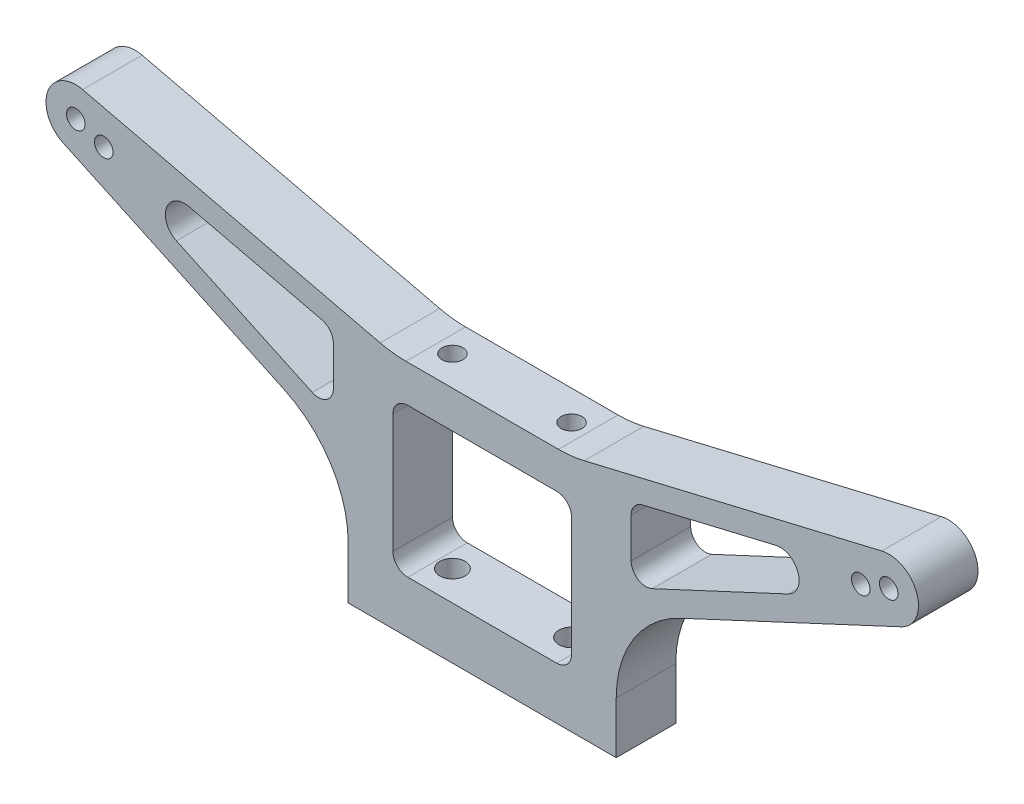
from build123d import *

# Parameters (mm, degrees)
SKETCH2_R                   = 0.5
SKETCH2_W                   = 24
SKETCH2_H                   = 20
BASE_DEPTH                  = 4
FILLET1_R                   = 2
M3_CLEARANCE_HOLE1_REACH    = 70.374
M3_CLEARANCE_HOLE1_BORE_R   = 1.7
TAP_DRILL_FOR_M3X0_5_TAP1_D = 2.5
SKETCH10_R                  = 1.4
CUT_EXTRUDE1_DEPTH          = 10


with BuildPart() as part:
    # Sketch2 → Base (new, symmetric)
    with BuildSketch(Plane.XY):
        with BuildLine():
            Line((18, 0), (-18, 0))
            Line((-18, 0), (-18, 6.963574124))
            ThreePointArc((-18, 6.963574124), (-20.349128313, 15.023068249), (-26.660726074, 20.558190929))
            Line((-26.660726074, 20.558190929), (-56.290473047, 34.374768852))
            ThreePointArc((-56.290473047, 34.374768852), (-58.378054978, 39.313887584), (-53.676261446, 41.891877064))
            Line((-53.676261446, 41.891877064), (-13.708280328, 32.405461008))
            ThreePointArc((-13.708280328, 32.405461008), (-11.988094908, 32.101710083), (-10.244260752, 32))
            Line((-10.244260752, 32), (10.244260752, 32))
            ThreePointArc((10.244260752, 32), (11.988094908, 32.101710083), (13.708280328, 32.405461008))
            Line((13.708280328, 32.405461008), (53.676261446, 41.891877064))
            ThreePointArc((53.676261446, 41.891877064), (58.378054978, 39.313887584), (56.290473047, 34.374768852))
            Line((56.290473047, 34.374768852), (26.660726074, 20.558190929))
            ThreePointArc((26.660726074, 20.558190929), (20.349128313, 15.023068249), (18, 6.963574124))
            Line((18, 6.963574124), (18, 0))
        make_face()
        with Locations((-54.6, 38)):
            Circle(SKETCH2_R, mode=Mode.SUBTRACT)
        with Locations(Location((54.6, 38, 0), (0, 0, 180))):
            Circle(SKETCH2_R, mode=Mode.SUBTRACT)
        with Locations((-50.841229517, 36.631919427)):
            Circle(SKETCH2_R, mode=Mode.SUBTRACT)
        with Locations(Location((50.841229517, 36.631919427, 0), (0, 0, 180))):
            Circle(SKETCH2_R, mode=Mode.SUBTRACT)
        with Locations((0, 17)):
            Rectangle(SKETCH2_W, SKETCH2_H, mode=Mode.SUBTRACT)
        with BuildLine():
            Line((-20, 23.901748263), (-20, 29.23459547))
            ThreePointArc((-20, 29.23459547), (-20.430965495, 30.474809453), (-21.538130723, 31.180534002))
            Line((-21.538130723, 31.180534002), (-39.406838724, 35.421678882))
            ThreePointArc((-39.406838724, 35.421678882), (-42.426006691, 33.766271599), (-41.085505358, 30.594709734))
            Line((-41.085505358, 30.594709734), (-22.845236523, 22.089132689))
            ThreePointArc((-22.845236523, 22.089132689), (-20.925400783, 22.214965371), (-20, 23.901748263))
        make_face(mode=Mode.SUBTRACT)
        with BuildLine():
            Line((20, 23.901748263), (20, 29.23459547))
            ThreePointArc((20, 29.23459547), (20.430965495, 30.474809453), (21.538130723, 31.180534002))
            Line((21.538130723, 31.180534002), (39.406838724, 35.421678882))
            ThreePointArc((39.406838724, 35.421678882), (42.426006691, 33.766271599), (41.085505358, 30.594709734))
            Line((41.085505358, 30.594709734), (22.845236523, 22.089132689))
            ThreePointArc((22.845236523, 22.089132689), (20.925400783, 22.214965371), (20, 23.901748263))
        make_face(mode=Mode.SUBTRACT)
    extrude(amount=BASE_DEPTH, both=True)

    # Fillet1
    fillet1_edges = [part.edges().sort_by_distance(p)[0] for p in [
        (-12, 27, 0),
        (-12, 7, 0),
        (12, 7, 0),
        (12, 27, 0),
    ]]
    fillet(fillet1_edges, radius=FILLET1_R)

    # M3 Clearance Hole1 bore → M3 Clearance Hole1 (cut, up to next)
    with BuildSketch(Plane(origin=(0, 7, 0), x_dir=(1, 0, 0), z_dir=(0, 1, 0)), mode=Mode.PRIVATE) as m3_clearance_hole1_sk1:
        with Locations((-8, 0)):
            Circle(M3_CLEARANCE_HOLE1_BORE_R)
    m3_clearance_hole1_tool1 = extrude(m3_clearance_hole1_sk1.sketch, amount=-M3_CLEARANCE_HOLE1_REACH, mode=Mode.PRIVATE) & part.part
    # M3 Clearance Hole1 bore → M3 Clearance Hole1 (cut, up to next)
    with BuildSketch(Plane(origin=(0, 7, 0), x_dir=(1, 0, 0), z_dir=(0, 1, 0)), mode=Mode.PRIVATE) as m3_clearance_hole1_sk2:
        with Locations((8, 0)):
            Circle(M3_CLEARANCE_HOLE1_BORE_R)
    m3_clearance_hole1_tool2 = extrude(m3_clearance_hole1_sk2.sketch, amount=-M3_CLEARANCE_HOLE1_REACH, mode=Mode.PRIVATE) & part.part
    add(m3_clearance_hole1_tool1.solids().sort_by_distance((-8, 7, 0))[0], mode=Mode.SUBTRACT)
    add(m3_clearance_hole1_tool2.solids().sort_by_distance((8, 7, 0))[0], mode=Mode.SUBTRACT)

    # Tap Drill for M3x0.5 Tap1 (through all)
    with Locations(Plane.XY.offset(4)):
        with Locations((-54.6, 38), (54.6, 38), (-50.841229517, 36.631919427), (50.841229517, 36.631919427)):
            Hole(TAP_DRILL_FOR_M3X0_5_TAP1_D / 2)

    # Sketch10 → Cut-Extrude1 (cut)
    with BuildSketch(Plane(origin=(0, 32, 0), x_dir=(1, 0, 0), z_dir=(0, 1, 0))):
        with Locations(Location((-8, 0, 0), (0, 0, 270))):
            Circle(SKETCH10_R)
        with Locations(Location((8, 0, 0), (0, 0, 270))):
            Circle(SKETCH10_R)
    extrude(amount=-CUT_EXTRUDE1_DEPTH, mode=Mode.SUBTRACT)


solid = part.part
